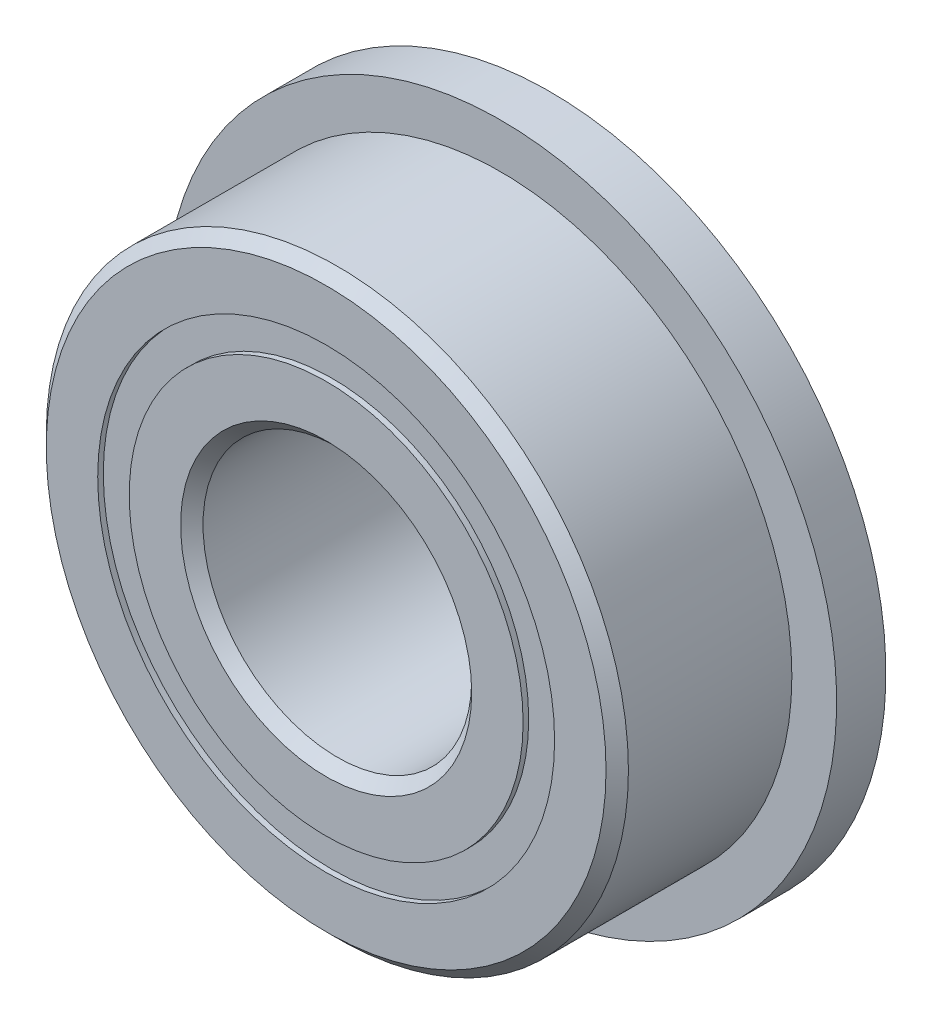
from build123d import *

# Parameters (mm, degrees)
CIRPATTERN1_COUNT = 12
SKETCH5_W         = 1.209571124
SKETCH5_H         = 0.703296704
SKETCH6_W         = 1.1
SKETCH6_H         = 2.398351648


with BuildPart() as part:
    # Sketch1 → Revolve1 (revolve)
    with BuildSketch(Plane(origin=(0, 0, 0), x_dir=(0, 0, -1), z_dir=(1, 0, 0))):
        with BuildLine():
            Line((2.25, 6.5), (-2.25, 6.5))
            Line((-2.25, 6.5), (-2.5, 6.25))
            Line((-2.5, 6.25), (-2.5, 5.101648352))
            Line((-2.5, 5.101648352), (-1.111111111, 5.101648352))
            ThreePointArc((-1.111111111, 5.101648352), (0, 5.915428876), (1.111111111, 5.101648352))
            Line((1.111111111, 5.101648352), (2.5, 5.101648352))
            Line((2.5, 5.101648352), (2.5, 6.25))
            Line((2.5, 6.25), (2.25, 6.5))
        make_face()
    revolve(axis=Axis((0, 0, 2.5), (0, 0, -1)))

    # Sketch6 → Revolve6 (revolve)
    with BuildSketch(Plane(origin=(0, 0, 0), x_dir=(0, 0, -1), z_dir=(1, 0, 0))):
        with Locations((1.95, 6.300824176)):
            Rectangle(SKETCH6_W, SKETCH6_H)
    revolve(axis=Axis((0, 0, -2.5), (0, 0, 1)))


with BuildPart() as body_2:
    # Sketch3 → Revolve3 (revolve)
    with BuildSketch(Plane(origin=(0, 0, 0), x_dir=(0, 0, -1), z_dir=(1, 0, 0))):
        with BuildLine():
            Line((-2.5, 4.398351648), (-1.111111111, 4.398351648))
            ThreePointArc((-1.111111111, 4.398351648), (0, 3.584571124), (1.111111111, 4.398351648))
            Line((1.111111111, 4.398351648), (2.5, 4.398351648))
            Line((2.5, 4.398351648), (2.5, 3.25))
            Line((2.5, 3.25), (2.25, 3))
            Line((2.25, 3), (-2.25, 3))
            Line((-2.25, 3), (-2.5, 3.25))
            Line((-2.5, 3.25), (-2.5, 4.398351648))
        make_face()
    revolve(axis=Axis((0, 0, 2.5), (0, 0, -1)))


with BuildPart() as body_3:
    # Sketch4 → Revolve4 (revolve)
    with BuildSketch(Plane(origin=(0, 0, 0), x_dir=(0, 0, -1), z_dir=(1, 0, 0))):
        with BuildLine():
            Line((-1.165428876, 4.75), (1.165428876, 4.75))
            ThreePointArc((1.165428876, 4.75), (0, 5.915428876), (-1.165428876, 4.75))
        make_face()
    revolve(axis=Axis((0, 4.75, 1.165428876), (0, 0, -1)))


with BuildPart() as cirpattern1_1:
    # CirPattern1: pattern copy
    add(body_3.part.rotate(Axis((0, 0, 0), (0, 0, 1)), 1 * 360 / CIRPATTERN1_COUNT))


with BuildPart() as cirpattern1_2:
    # CirPattern1: pattern copy
    add(body_3.part.rotate(Axis((0, 0, 0), (0, 0, 1)), 2 * 360 / CIRPATTERN1_COUNT))


with BuildPart() as cirpattern1_3:
    # CirPattern1: pattern copy
    add(body_3.part.rotate(Axis((0, 0, 0), (0, 0, 1)), 3 * 360 / CIRPATTERN1_COUNT))


with BuildPart() as cirpattern1_4:
    # CirPattern1: pattern copy
    add(body_3.part.rotate(Axis((0, 0, 0), (0, 0, 1)), 4 * 360 / CIRPATTERN1_COUNT))


with BuildPart() as cirpattern1_5:
    # CirPattern1: pattern copy
    add(body_3.part.rotate(Axis((0, 0, 0), (0, 0, 1)), 5 * 360 / CIRPATTERN1_COUNT))


with BuildPart() as cirpattern1_6:
    # CirPattern1: pattern copy
    add(body_3.part.rotate(Axis((0, 0, 0), (0, 0, 1)), 6 * 360 / CIRPATTERN1_COUNT))


with BuildPart() as cirpattern1_7:
    # CirPattern1: pattern copy
    add(body_3.part.rotate(Axis((0, 0, 0), (0, 0, 1)), 7 * 360 / CIRPATTERN1_COUNT))


with BuildPart() as cirpattern1_8:
    # CirPattern1: pattern copy
    add(body_3.part.rotate(Axis((0, 0, 0), (0, 0, 1)), 8 * 360 / CIRPATTERN1_COUNT))


with BuildPart() as cirpattern1_9:
    # CirPattern1: pattern copy
    add(body_3.part.rotate(Axis((0, 0, 0), (0, 0, 1)), 9 * 360 / CIRPATTERN1_COUNT))


with BuildPart() as cirpattern1_10:
    # CirPattern1: pattern copy
    add(body_3.part.rotate(Axis((0, 0, 0), (0, 0, 1)), 10 * 360 / CIRPATTERN1_COUNT))


with BuildPart() as cirpattern1_11:
    # CirPattern1: pattern copy
    add(body_3.part.rotate(Axis((0, 0, 0), (0, 0, 1)), 11 * 360 / CIRPATTERN1_COUNT))


with BuildPart() as body_15:
    # Sketch5 → Revolve5 (revolve)
    with BuildSketch(Plane(origin=(0, 0, 0), x_dir=(0, 0, -1), z_dir=(1, 0, 0))):
        with Locations((-1.770214438, 4.75)):
            Rectangle(SKETCH5_W, SKETCH5_H)
        with Locations((1.770214438, 4.75)):
            Rectangle(SKETCH5_W, SKETCH5_H)
    revolve(axis=Axis((0, 0, 2.5), (0, 0, -1)))


solid = Compound([part.part, body_2.part, body_3.part, cirpattern1_1.part, cirpattern1_2.part, cirpattern1_3.part, cirpattern1_4.part, cirpattern1_5.part, cirpattern1_6.part, cirpattern1_7.part, cirpattern1_8.part, cirpattern1_9.part, cirpattern1_10.part, cirpattern1_11.part, body_15.part])
